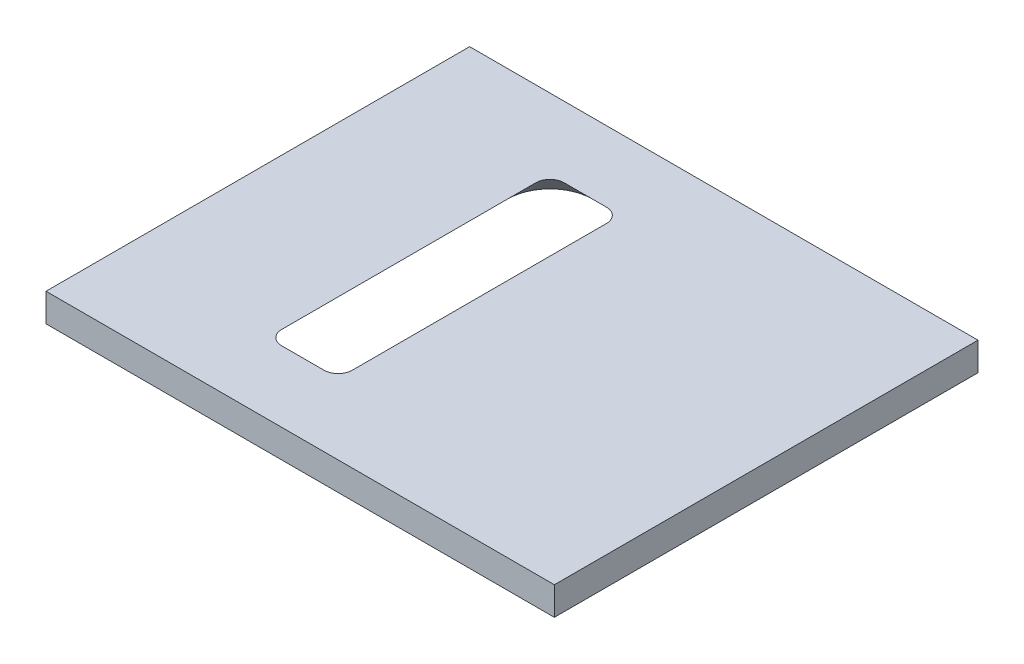
from build123d import *

# Parameters (mm, degrees)
SKETCH2_W           = 36
SKETCH2_H           = 30
BOSS_EXTRUDE1_DEPTH = 2
CUT_EXTRUDE4_DEPTH  = 3
CUT_EXTRUDE4_TAPER  = -45


with BuildPart() as part:
    # Sketch2 → Boss-Extrude1 (new body)
    with BuildSketch(Plane(origin=(0, 0, 0), x_dir=(1, 0, 0), z_dir=(0, 1, 0))):
        with Locations((4.811028754, 0)):
            Rectangle(SKETCH2_W, SKETCH2_H)
    extrude(amount=BOSS_EXTRUDE1_DEPTH)

    # Sketch4 → Cut-Extrude4 (cut, through all)
    with BuildSketch(Plane(origin=(0, 2, 0), x_dir=(1, 0, 0), z_dir=(0, 1, 0))):
        with BuildLine():
            ThreePointArc((1.5, -10), (2.207106781, -9.707106781), (2.5, -9))
            Line((2.5, -9), (2.5, 9))
            ThreePointArc((2.5, 9), (2.207106781, 9.707106781), (1.5, 10))
            Line((1.5, 10), (-1.5, 10))
            ThreePointArc((-1.5, 10), (-2.207106781, 9.707106781), (-2.5, 9))
            Line((-2.5, 9), (-2.5, -9))
            ThreePointArc((-2.5, -9), (-2.207106781, -9.707106781), (-1.5, -10))
            Line((-1.5, -10), (1.5, -10))
        make_face()
    extrude(amount=-CUT_EXTRUDE4_DEPTH, taper=CUT_EXTRUDE4_TAPER, mode=Mode.SUBTRACT)


solid = part.part
